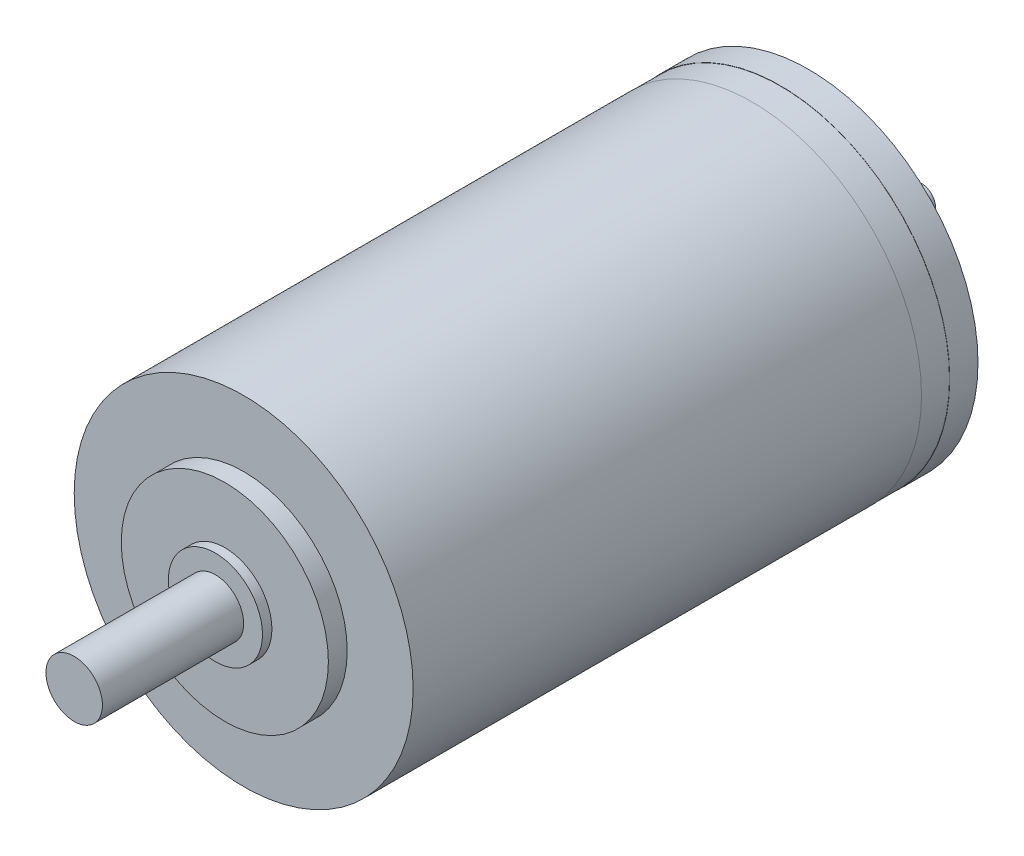
from build123d import *

# Parameters (mm, degrees)
SKETCH_1_R       = 17.975
EXTRUDE_1_DEPTH  = 3
SKETCH_2_R       = 18
EXTRUDE_2_DEPTH  = 50
SKETCH_3_R       = 18
EXTRUDE_3_DEPTH  = 4
SKETCH_4_R       = 11
EXTRUDE_4_DEPTH  = 2
SKETCH_5_R       = 5
EXTRUDE_6_DEPTH  = 1
SKETCH_6_R       = 3
EXTRUDE_7_DEPTH  = 15
SKETCH_8_R       = 18
EXTRUDE_9_DEPTH  = 3
SKETCH_9_R       = 5
EXTRUDE_10_DEPTH = 2
SKETCH_10_R      = 1.5
EXTRUDE_11_DEPTH = 10


with BuildPart() as part:
    # 草圖1 → 填料-伸長1 (new body)
    with BuildSketch(Plane.XY):
        Circle(SKETCH_1_R)
    extrude(amount=EXTRUDE_1_DEPTH)

    # 草圖2 → 填料-伸長2 (add)
    with BuildSketch(Plane.XY.offset(3)):
        Circle(SKETCH_2_R)
    extrude(amount=EXTRUDE_2_DEPTH)

    # 草圖3 → 填料-伸長3 (add)
    with BuildSketch(Plane.XY.offset(53)):
        Circle(SKETCH_3_R)
    extrude(amount=EXTRUDE_3_DEPTH)

    # 草圖4 → 填料-伸長4 (add)
    with BuildSketch(Plane.XY.offset(57)):
        Circle(SKETCH_4_R)
    extrude(amount=EXTRUDE_4_DEPTH)

    # 草圖5 → 填料-伸長6 (add)
    with BuildSketch(Plane.XY.offset(59)):
        Circle(SKETCH_5_R)
    extrude(amount=EXTRUDE_6_DEPTH)

    # 草圖6 → 填料-伸長7 (add)
    with BuildSketch(Plane.XY.offset(60)):
        Circle(SKETCH_6_R)
    extrude(amount=EXTRUDE_7_DEPTH)

    # 草圖8 → 填料-伸長9 (add)
    with BuildSketch(Plane(origin=(0, 0, 0), x_dir=(-1, 0, 0), z_dir=(0, 0, -1))):
        Circle(SKETCH_8_R)
    extrude(amount=EXTRUDE_9_DEPTH)

    # 草圖9 → 填料-伸長10 (add)
    with BuildSketch(Plane(origin=(0, 0, -3), x_dir=(-1, 0, 0), z_dir=(0, 0, -1))):
        Circle(SKETCH_9_R)
    extrude(amount=EXTRUDE_10_DEPTH)

    # 草圖10 → 填料-伸長11 (add)
    with BuildSketch(Plane(origin=(0, 0, -5), x_dir=(-1, 0, 0), z_dir=(0, 0, -1))):
        Circle(SKETCH_10_R)
    extrude(amount=EXTRUDE_11_DEPTH)


solid = part.part
